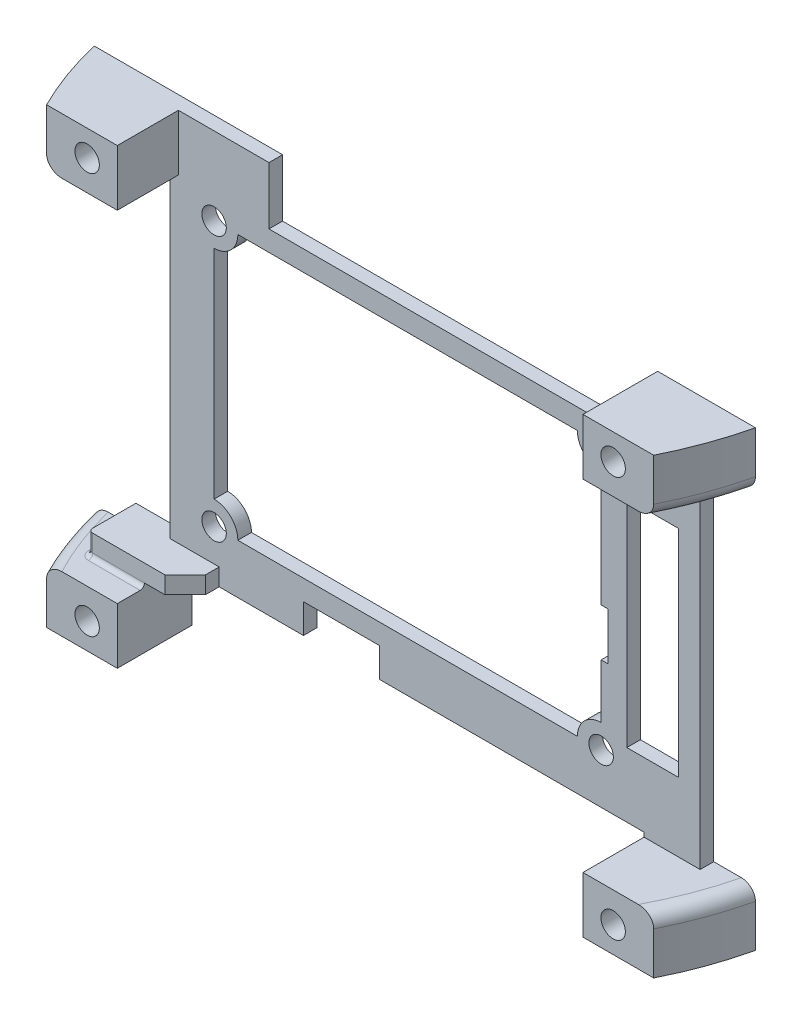
from build123d import *

# Parameters (mm, degrees)
EXTRUDE_1_DEPTH             = 8.255
EXTRUDE_2_DEPTH             = 50.165
CUT_EXTRUDE_1_DEPTH         = 50.165
EXTRUDE_3_DEPTH             = 8.255
CUT_EXTRUDE_2_DEPTH         = 8.255
CUT_EXTRUDE_3_DEPTH         = 8.255
CUT_EXTRUDE_4_DEPTH         = 55.245
CUT_EXTRUDE_5_DEPTH         = 0.635
CUT_EXTRUDE_6_DEPTH         = 46.99
SKETCH_10_W                 = 8.255
SKETCH_10_H                 = 4
EXTRUDE_4_DEPTH             = 0.635
CUT_EXTRUDE_7_DEPTH         = 2
EXTRUDE_5_DEPTH             = 8.255
SKETCH_13_W                 = 11.176
SKETCH_13_H                 = 4.318
CUT_EXTRUDE_8_DEPTH         = 3
CUT_EXTRUDE_9_DEPTH         = 12
SKETCH_15_W                 = 7.62
SKETCH_15_H                 = 31.75
CUT_EXTRUDE_10_DEPTH        = 3
HOLE_WIZARD_3_6_3_6_1_D     = 3.6
HOLE_WIZARD_3_6_3_6_1_DEPTH = 11
HOLE_WIZARD_3_6_3_6_2_D     = 3.6
HOLE_WIZARD_3_6_3_6_2_DEPTH = 11
FILLET_1_R                  = 0.635
FILLET_2_R                  = 2


with BuildPart() as part:
    # 草图1 → 凸台-拉伸1 (new body)
    with BuildSketch(Plane.XZ.offset(-25.0825)):
        with BuildLine():
            Line((729.045, 11), (729.045, 4))
            Line((729.045, 4), (721.71, 4))
            Line((721.71, 4), (718.71, 7))
            Line((718.71, 7), (715.71, 7))
            Line((715.71, 7), (715.71, 11))
            Line((715.71, 11), (705.298322179, 11))
            ThreePointArc((705.298322179, 11), (702.984819943, 5.616840019), (701.316943399, 0))
            Line((701.316943399, 0), (798.683056601, 0))
            ThreePointArc((798.683056601, 0), (797.015180057, 5.616840019), (794.701677821, 11))
            Line((794.701677821, 11), (729.045, 11))
        make_face()
    extrude(amount=-EXTRUDE_1_DEPTH)

    # 草图2 → 凸台-拉伸2 (add)
    with BuildSketch(Plane.XZ.offset(-25.0825)):
        with BuildLine():
            Line((705.298322179, 11), (715.71, 11))
            Line((715.71, 11), (715.71, 7))
            Line((715.71, 7), (718.71, 7))
            Line((718.71, 7), (721.71, 4))
            Line((721.71, 4), (792.545, 4))
            Line((792.545, 4), (792.545, 0))
            Line((792.545, 0), (701.316943399, 0))
            ThreePointArc((701.316943399, 0), (702.984819943, 5.616840019), (705.298322179, 11))
        make_face()
    extrude(amount=EXTRUDE_2_DEPTH)

    # 草图3 → 切除-拉伸1 (cut)
    with BuildSketch(Plane.XZ.offset(25.0825)):
        with BuildLine():
            Line((701.316943399, 0), (707.455, 0))
            Line((707.455, 0), (707.455, 7))
            Line((707.455, 7), (715.71, 7))
            Line((715.71, 7), (715.71, 11))
            Line((715.71, 11), (705.298322179, 11))
            ThreePointArc((705.298322179, 11), (702.984819943, 5.616840019), (701.316943399, 0))
        make_face()
    extrude(amount=-CUT_EXTRUDE_1_DEPTH, mode=Mode.SUBTRACT)

    # 草图4 → 凸台-拉伸3 (add)
    with BuildSketch(Plane.XZ.offset(25.0825)):
        with BuildLine():
            Line((705.298322179, 11), (715.71, 11))
            Line((715.71, 11), (715.71, 7))
            Line((715.71, 7), (718.71, 7))
            Line((718.71, 7), (721.71, 4))
            Line((721.71, 4), (792.545, 4))
            Line((792.545, 4), (792.545, 0))
            Line((792.545, 0), (701.316943399, 0))
            ThreePointArc((701.316943399, 0), (702.984819943, 5.616840019), (705.298322179, 11))
        make_face()
    extrude(amount=EXTRUDE_3_DEPTH)

    # 草图5 → 切除-拉伸2 (cut)
    with BuildSketch(Plane(origin=(0, 33.3375, 0), x_dir=(-1, 0, 0), z_dir=(0, 1, 0))):
        Polygon((-721.71, 4), (-715.71, 4), (-715.71, 7), (-718.71, 7), align=None)
    extrude(amount=-CUT_EXTRUDE_2_DEPTH, mode=Mode.SUBTRACT)

    # 草图6 → 切除-拉伸3 (cut)
    with BuildSketch(Plane.XZ.offset(33.3375)):
        Polygon((715.71, 0), (792.545, 0), (792.545, 4), (721.71, 4), (718.71, 7), (715.71, 7), align=None)
    extrude(amount=-CUT_EXTRUDE_3_DEPTH, mode=Mode.SUBTRACT)

    # 草图7 → 切除-拉伸4 (cut)
    with BuildSketch(Plane.ZY.offset(-729.045)):
        Polygon((0, 33.3375), (0, 24.8705), (4, 24.8705), (4, 25.0825), (11, 25.0825), (11, 33.3375), align=None)
    extrude(amount=-CUT_EXTRUDE_4_DEPTH, mode=Mode.SUBTRACT)

    # 草图8 → 切除-拉伸5 (cut)
    with BuildSketch(Plane.XZ.offset(25.0825)):
        Polygon((715.71, 0), (792.545, 0), (792.545, 4), (721.71, 4), (718.71, 7), (715.71, 7), align=None)
    extrude(amount=-CUT_EXTRUDE_5_DEPTH, mode=Mode.SUBTRACT)

    # 草图9 → 切除-拉伸6 (cut)
    with BuildSketch(Plane(origin=(0, 25.0825, 0), x_dir=(-1, 0, 0), z_dir=(0, 1, 0))):
        Polygon((-721.71, 4), (-714.44, 4), (-714.44, 0), (-707.455, 0), (-707.455, 7), (-718.71, 7), align=None)
    extrude(amount=-CUT_EXTRUDE_6_DEPTH, mode=Mode.SUBTRACT)

    # 草图10 → 凸台-拉伸4 (add)
    with BuildSketch(Plane.XZ.offset(24.4475)):
        with Locations((788.4175, 2)):
            Rectangle(SKETCH_10_W, SKETCH_10_H)
    extrude(amount=EXTRUDE_4_DEPTH)

    # 草图11 → 切除-拉伸7 (cut)
    with BuildSketch(Plane.XY.offset(4)):
        Polygon((784.29, 25.0825), (784.29, 24.8705), (729.045, 24.8705), (729.045, 33.3375), (715.71, 33.3375), (715.71, 25.0825), (714.44, 25.0825), (714.44, -21.9075), (721.71, -21.9075), (721.71, -24.4475), (784.29, -24.4475), (784.29, -25.0825), (792.545, -25.0825), (792.545, 25.0825), align=None)
    extrude(amount=-CUT_EXTRUDE_7_DEPTH, mode=Mode.SUBTRACT)

    # 草图12 → 凸台-拉伸5 (add)
    with BuildSketch(Plane.XZ.offset(25.0825)):
        with BuildLine():
            Line((798.683056601, 0), (784.29, 0))
            Line((784.29, 0), (784.29, 11))
            Line((784.29, 11), (794.701677821, 11))
            ThreePointArc((794.701677821, 11), (797.015180057, 5.616840019), (798.683056601, 0))
        make_face()
    extrude(amount=EXTRUDE_5_DEPTH)

    # 草图13 → 切除-拉伸8 (cut, through all)
    with BuildSketch(Plane.XY.offset(2)):
        with Locations((739.713, -22.2885)):
            Rectangle(SKETCH_13_W, SKETCH_13_H)
    extrude(amount=-CUT_EXTRUDE_8_DEPTH, mode=Mode.SUBTRACT)

    # 草图14 → 切除-拉伸9 (cut, through all)
    with BuildSketch(Plane(origin=(0, 0, 0), x_dir=(-1, 0, 0), z_dir=(0, 0, -1))):
        with BuildLine():
            Line((-777.963, 18.3705), (-777.963, 1.3705))
            Line((-777.963, 1.3705), (-778.963, 1.3705))
            Line((-778.963, 1.3705), (-778.963, -5.6295))
            Line((-778.963, -5.6295), (-777.963, -5.6295))
            Line((-777.963, -5.6295), (-777.963, -13.6295))
            ThreePointArc((-777.963, -13.6295), (-775.488126266, -14.654626266), (-774.463, -17.1295))
            Line((-774.463, -17.1295), (-724.463, -17.1295))
            ThreePointArc((-724.463, -17.1295), (-723.437873734, -14.654626266), (-720.963, -13.6295))
            Line((-720.963, -13.6295), (-720.963, 18.3705))
            ThreePointArc((-720.963, 18.3705), (-723.437873734, 19.395626266), (-724.463, 21.8705))
            Line((-724.463, 21.8705), (-774.463, 21.8705))
            ThreePointArc((-774.463, 21.8705), (-775.488126266, 19.395626266), (-777.963, 18.3705))
        make_face()
    extrude(amount=-CUT_EXTRUDE_9_DEPTH, mode=Mode.SUBTRACT)

    # 草图15 → 切除-拉伸10 (cut, through all)
    with BuildSketch(Plane.XY.offset(2)):
        with Locations((785.56, 0.9525)):
            Rectangle(SKETCH_15_W, SKETCH_15_H)
    extrude(amount=-CUT_EXTRUDE_10_DEPTH, mode=Mode.SUBTRACT)

    # Ø3.6 (3.6) 直径孔1
    with Locations(Plane(origin=(0, 0, 0), x_dir=(-1, 0, 0), z_dir=(0, 0, -1))):
        with Locations((-711.265, 29.5275), (-788.735, 29.5275), (-788.735, -29.5275), (-711.265, -29.5275)):
            Hole(HOLE_WIZARD_3_6_3_6_1_D / 2, depth=HOLE_WIZARD_3_6_3_6_1_DEPTH)

    # Ø3.6 (3.6) 直径孔2
    with Locations(Plane(origin=(0, 0, 0), x_dir=(-1, 0, 0), z_dir=(0, 0, -1))):
        with Locations((-720.963, -17.1295), (-720.963, 21.8705), (-777.963, 21.8705), (-777.963, -17.1295)):
            Hole(HOLE_WIZARD_3_6_3_6_2_D / 2, depth=HOLE_WIZARD_3_6_3_6_2_DEPTH)

    # 圆角1
    fillet_1_edges = [part.edges().sort_by_distance(p)[0] for p in [
        (711.5825, -25.0825, 7),
        (707.455, -23.495, 7),
        (707.455, -25.0825, 3.5),
    ]]
    fillet(fillet_1_edges, radius=FILLET_1_R)

    # 圆角2
    fillet_2_edges = [part.edges().sort_by_distance(p)[0] for p in [
        (797.015180057, -25.0825, 5.616840019),
        (702.984819943, 25.0825, 5.616840019),
        (702.984819943, -25.0825, 5.616840019),
        (797.015180057, 25.0825, 5.616840019),
    ]]
    fillet(fillet_2_edges, radius=FILLET_2_R)


solid = part.part
